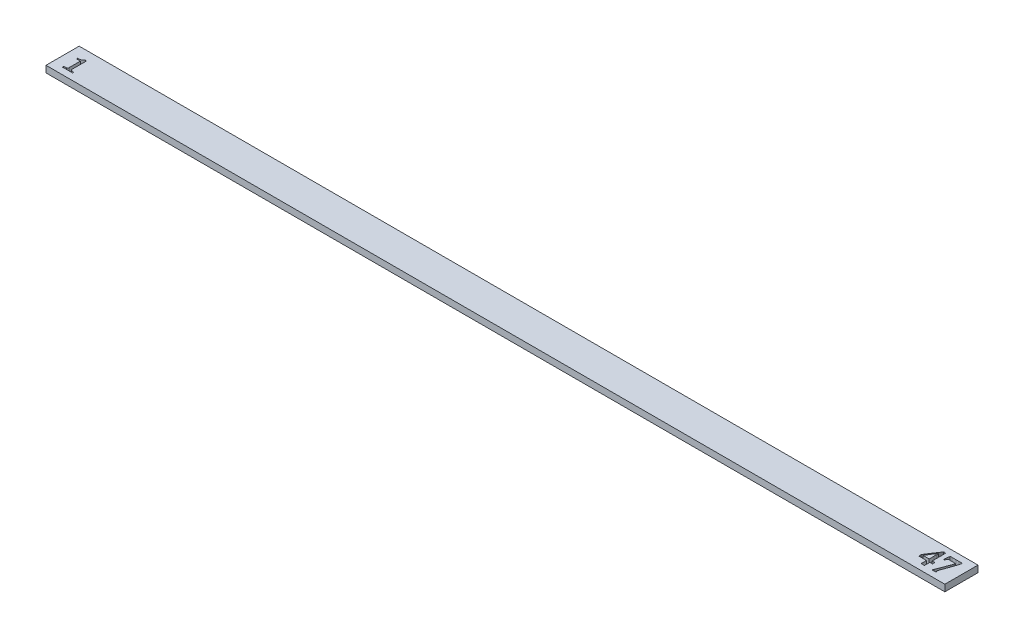
from build123d import *

# Parameters (mm, degrees)
SKETCH1_W               = 406.5
SKETCH1_H               = 15
BOSS_EXTRUDE1_DEPTH     = 3
CUT_EXTRUDE3_DEPTH      = 3
CUT_EXTRUDE4_DEPTH      = 1.0000001
CUT_EXTRUDE4_DEPTH_BACK = 4.0000001


with BuildPart() as part:
    # Sketch1 → Boss-Extrude1 (new body)
    with BuildSketch(Plane(origin=(0, 0, 0), x_dir=(1, 0, 0), z_dir=(0, 1, 0))):
        with Locations((203.25, 7.5)):
            Rectangle(SKETCH1_W, SKETCH1_H)
    extrude(amount=BOSS_EXTRUDE1_DEPTH)

    # Sketch6 → Cut-Extrude3 (cut)
    with BuildSketch(Plane(origin=(0, 3, 0), x_dir=(1, 0, 0), z_dir=(0, 1, 0))):
        with BuildLine():
            Line((9.066666667, 3), (4.4, 3))
            Line((4.4, 3), (4.4, 3.533333333))
            add(Edge.make_bspline(
                [(4.4, 3.533333333), (4.490588794, 3.537271225), (4.640939574, 3.554398669), (4.861223058, 3.573162067), (5.060458421, 3.593917618), (5.257445963, 3.613512622), (5.464614035, 3.645285276), (5.602979352, 3.665934489), (5.68125, 3.689583333)],
                knots=[0, 0, 0, 0, 0.2103903, 0.351266804, 0.513317769, 0.675537116, 0.81076344, 1, 1, 1, 1], degree=3))
            add(Edge.make_bspline(
                [(5.68125, 3.689583333), (5.748875075, 3.713315135), (5.846065039, 3.75657282), (5.954177233, 3.84358762), (6.019880095, 3.92035001), (6.074718504, 4.012338083), (6.121751402, 4.174441728), (6.136210364, 4.307279756), (6.133333333, 4.402083333)],
                knots=[0, 0, 0, 0, 0.235250595, 0.343488261, 0.45143933, 0.564460817, 0.690934998, 1, 1, 1, 1], degree=3))
            Line((6.133333333, 4.402083333), (6.133333333, 9.4))
            Line((6.133333333, 9.4), (4.4, 9.4))
            Line((4.4, 9.4), (4.4, 9.933333333))
            Line((4.4, 9.933333333), (4.770833333, 9.933333333))
            add(Edge.make_bspline(
                [(4.770833333, 9.933333333), (5.003253924, 9.932619455), (5.34569499, 9.96889158), (5.780241549, 10.092243553), (6.074213986, 10.222394513), (6.33996875, 10.370119885), (6.630202894, 10.569224178), (6.814157432, 10.739590824), (6.90625, 10.866666667)],
                knots=[0, 0, 0, 0, 0.289649108, 0.426683234, 0.561657866, 0.689592667, 0.805376187, 1, 1, 1, 1], degree=3))
            Line((6.90625, 10.866666667), (7.466666667, 10.866666667))
            add(Edge.make_bspline(
                [(7.466666667, 10.866666667), (7.466666667, 10.7), (7.466666667, 10.440277778), (7.466666667, 10.080555556), (7.466666667, 9.51875), (7.466666667, 9.05), (7.466666667, 8.68125)],
                knots=[0, 0, 0, 0, 0.228789323, 0.356530029, 0.493803622, 1, 1, 1, 1], degree=3))
            Line((7.466666667, 8.68125), (7.466666667, 4.477083333))
            add(Edge.make_bspline(
                [(7.466666667, 4.477083333), (7.465171299, 4.323802417), (7.508915415, 4.1322322), (7.627640514, 3.94057428), (7.725471426, 3.836074847), (7.81353907, 3.774674671), (7.879166667, 3.745833333)],
                knots=[0, 0, 0, 0, 0.518335827, 0.640811583, 0.758815486, 1, 1, 1, 1], degree=3))
            add(Edge.make_bspline(
                [(7.879166667, 3.745833333), (7.9542548, 3.71328483), (8.086144111, 3.677803773), (8.281176448, 3.634356203), (8.460811746, 3.603704136), (8.641304858, 3.575188457), (8.843360346, 3.550303966), (8.982249303, 3.535230482), (9.066666667, 3.533333333)],
                knots=[0, 0, 0, 0, 0.202205355, 0.337957571, 0.495327151, 0.653832039, 0.790920356, 1, 1, 1, 1], degree=3))
            Line((9.066666667, 3.533333333), (9.066666667, 3))
        make_face()
    extrude(amount=-CUT_EXTRUDE3_DEPTH, mode=Mode.SUBTRACT)

    # Sketch7 → Cut-Extrude4 (cut, two sides)
    with BuildSketch(Plane(origin=(0, 3, 0), x_dir=(1, 0, 0), z_dir=(0, 1, 0))) as cut_extrude4_sk:
        with BuildLine():
            Line((397.657416045, 12.134328358), (399.36170709, 12.119636194))
            Line((399.36170709, 12.119636194), (400.80363806, 12.134328358))
            Line((400.80363806, 12.134328358), (401.630597015, 12.134328358))
            Line((401.630597015, 12.134328358), (401.916044776, 12.134328358))
            add(Edge.make_bspline(
                [(401.916044776, 12.134328358), (402.048274254, 12.134328358), (402.180503731, 12.134328358)],
                knots=[0, 0, 0, 1, 1, 1], degree=2))
            add(Edge.make_bspline(
                [(402.180503731, 12.134328358), (402.201575998, 11.924942161), (402.201492537, 11.714552239)],
                knots=[0, 0, 0, 1, 1, 1], degree=2))
            add(Edge.make_bspline(
                [(402.201492537, 11.714552239), (402.203131347, 11.668589183), (402.19068364, 11.591838207), (402.174063032, 11.47775602), (402.152159642, 11.365919222), (402.12514035, 11.236424374), (402.077258352, 11.028335682), (402.035714677, 10.864320831), (402.006296642, 10.749067164)],
                knots=[0, 0, 0, 0, 0.13905043, 0.235945899, 0.350700723, 0.485483275, 0.63825942, 1, 1, 1, 1], degree=3))
            add(Edge.make_bspline(
                [(402.006296642, 10.749067164), (401.871316102, 10.385817027), (401.722590265, 9.935527531), (401.555047554, 9.414875731), (401.473187852, 9.159276866), (401.414575292, 8.9873101), (401.376632463, 8.885261194)],
                knots=[0, 0, 0, 0, 0.59075753, 0.723007296, 0.834001471, 1, 1, 1, 1], degree=3))
            add(Edge.make_bspline(
                [(401.376632463, 8.885261194), (401.313898269, 8.723451669), (401.204868261, 8.421855137), (401.103802997, 8.117485745), (401.061800373, 7.976445896)],
                knots=[0, 0, 0, 0, 0.541149528, 1, 1, 1, 1], degree=3))
            add(Edge.make_bspline(
                [(401.061800373, 7.976445896), (401.015781111, 7.867199658), (400.92613119, 7.624150454), (400.836545299, 7.38111444), (400.791044776, 7.248134328)],
                knots=[0, 0, 0, 0, 0.457478678, 1, 1, 1, 1], degree=3))
            Line((400.791044776, 7.248134328), (400.440531716, 6.251166045))
            add(Edge.make_bspline(
                [(400.440531716, 6.251166045), (400.401867219, 6.128988579), (400.289271875, 5.818532343), (400.177344913, 5.507885229), (400.104710821, 5.31926306)],
                knots=[0, 0, 0, 0, 0.387977624, 1, 1, 1, 1], degree=3))
            Line((400.104710821, 5.31926306), (399.531716418, 3.703125))
            add(Edge.make_bspline(
                [(399.531716418, 3.703125), (399.470792091, 3.588260157), (399.458255597, 3.459654851)],
                knots=[0, 0, 0, 1, 1, 1], degree=2))
            add(Edge.make_bspline(
                [(399.458255597, 3.459654851), (399.459359318, 3.418786808), (399.483917308, 3.355260387), (399.551474188, 3.28641717), (399.619265243, 3.234969283), (399.68890107, 3.185275189), (399.756975495, 3.118645064), (399.782530612, 3.05647035), (399.78358209, 3.016791045)],
                knots=[0, 0, 0, 0, 0.213120215, 0.343422421, 0.503306522, 0.66092689, 0.793754467, 1, 1, 1, 1], degree=3))
            add(Edge.make_bspline(
                [(399.78358209, 3.016791045), (399.782333582, 2.966918943), (399.738145153, 2.854647526), (399.649224406, 2.773694486), (399.596781716, 2.731343284)],
                knots=[0, 0, 0, 0, 0.419347253, 1, 1, 1, 1], degree=3))
            Line((399.596781716, 2.731343284), (399.414179104, 2.731343284))
            Line((399.414179104, 2.731343284), (398.887360075, 2.739738806))
            add(Edge.make_bspline(
                [(398.887360075, 2.739738806), (398.860151379, 2.742883209), (398.809019878, 2.741140263), (398.727094991, 2.742934339), (398.564977408, 2.731719862), (398.426269692, 2.734390124), (398.318563433, 2.731343284)],
                knots=[0, 0, 0, 0, 0.143976302, 0.269387033, 0.431850849, 1, 1, 1, 1], degree=3))
            add(Edge.make_bspline(
                [(398.318563433, 2.731343284), (398.177938433, 2.731343284), (398.037313433, 2.731343284)],
                knots=[0, 0, 0, 1, 1, 1], degree=2))
            add(Edge.make_bspline(
                [(398.037313433, 2.731343284), (398.049687067, 2.837793441), (398.135988461, 3.107690529), (398.252282772, 3.364778234), (398.324860075, 3.524720149)],
                knots=[0, 0, 0, 0, 0.377761085, 1, 1, 1, 1], degree=3))
            add(Edge.make_bspline(
                [(398.324860075, 3.524720149), (398.359194022, 3.604153438), (398.416976822, 3.739859696), (398.497461012, 3.945705724), (398.576766977, 4.150868746), (398.669922308, 4.390270462), (398.814377186, 4.778720373), (398.926619167, 5.087912153), (399.006996269, 5.304570896)],
                knots=[0, 0, 0, 0, 0.136189941, 0.232079304, 0.347806246, 0.482346311, 0.636338705, 1, 1, 1, 1], degree=3))
            Line((399.006996269, 5.304570896), (400.264225746, 8.69426306))
            Line((400.264225746, 8.69426306), (400.579057836, 9.559001866))
            add(Edge.make_bspline(
                [(400.579057836, 9.559001866), (400.616057825, 9.635348826), (400.685585318, 9.816861246), (400.749296629, 10.000359879), (400.782649254, 10.104710821)],
                knots=[0, 0, 0, 0, 0.436195377, 1, 1, 1, 1], degree=3))
            add(Edge.make_bspline(
                [(400.782649254, 10.104710821), (400.796446887, 10.155676607), (400.848863125, 10.278905641), (400.884307376, 10.408166699), (400.916977612, 10.482509328)],
                knots=[0, 0, 0, 0, 0.394055214, 1, 1, 1, 1], degree=3))
            add(Edge.make_bspline(
                [(400.916977612, 10.482509328), (400.707169462, 10.494052768), (400.331609443, 10.511600567), (399.95577418, 10.523472847), (399.789878731, 10.52238806)],
                knots=[0, 0, 0, 0, 0.558858828, 1, 1, 1, 1], degree=3))
            Line((399.789878731, 10.52238806), (398.734141791, 10.505597015))
            Line((398.734141791, 10.505597015), (397.890391791, 10.52238806))
            add(Edge.make_bspline(
                [(397.890391791, 10.52238806), (397.779523901, 10.519107819), (397.623281613, 10.516165209), (397.443939678, 10.457590251), (397.347926059, 10.402046043), (397.280071966, 10.318527079), (397.225882193, 10.21568689), (397.182311943, 10.088092188), (397.153666964, 9.944727335), (397.127648786, 9.805193063), (397.098045358, 9.686069457), (397.062105015, 9.598330089), (397.027739987, 9.531559532), (396.976868027, 9.493930387), (396.895857316, 9.451249493), (396.819667629, 9.45247622), (396.769589552, 9.447761194)],
                knots=[0, 0, 0, 0, 0.189212858, 0.259177039, 0.317618741, 0.37382617, 0.438411826, 0.513621268, 0.600883716, 0.685342077, 0.753932297, 0.80753941, 0.846294416, 0.878260495, 0.912652405, 1, 1, 1, 1], degree=3))
            add(Edge.make_bspline(
                [(396.769589552, 9.447761194), (396.709575572, 9.444087607), (396.572553162, 9.510974529), (396.561202473, 9.664537833), (396.559701493, 9.733208955)],
                knots=[0, 0, 0, 0, 0.447088882, 1, 1, 1, 1], degree=3))
            add(Edge.make_bspline(
                [(396.559701493, 9.733208955), (396.557663158, 9.882622623), (396.585872177, 10.242409551), (396.612263822, 10.602114141), (396.639458955, 10.812033582)],
                knots=[0, 0, 0, 0, 0.413664263, 1, 1, 1, 1], degree=3))
            add(Edge.make_bspline(
                [(396.639458955, 10.812033582), (396.674306511, 11.049653107), (396.71198534, 11.491672506), (396.756641484, 11.933109174), (396.788479478, 12.134328358)],
                knots=[0, 0, 0, 0, 0.541004894, 1, 1, 1, 1], degree=3))
            add(Edge.make_bspline(
                [(396.788479478, 12.134328358), (396.907416045, 12.134328358), (397.197061567, 12.134328358), (397.48670709, 12.134328358), (397.657416045, 12.134328358)],
                knots=[0, 0, 0, 0, 0.410628019, 1, 1, 1, 1], degree=3))
        make_face()
        with BuildLine():
            Line((395.753731343, 6.223880597), (395.753731343, 5.149253731))
            add(Edge.make_bspline(
                [(395.753731343, 5.149253731), (395.631296642, 5.149253731), (395.415811567, 5.149253731), (395.200326493, 5.149253731), (395.107276119, 5.149253731)],
                knots=[0, 0, 0, 0, 0.568181818, 1, 1, 1, 1], degree=3))
            add(Edge.make_bspline(
                [(395.107276119, 5.149253731), (394.826026119, 5.149253731), (394.544776119, 5.149253731)],
                knots=[0, 0, 0, 1, 1, 1], degree=2))
            add(Edge.make_bspline(
                [(394.544776119, 5.149253731), (394.544776119, 5.103078358), (394.544776119, 5.033815299), (394.544776119, 4.964552239), (394.544776119, 4.941464552)],
                knots=[0, 0, 0, 0, 0.666666667, 1, 1, 1, 1], degree=3))
            Line((394.544776119, 4.941464552), (394.544776119, 4.51329291))
            Line((394.544776119, 4.51329291), (394.544776119, 4.05573694))
            Line((394.544776119, 4.05573694), (394.544776119, 3.740904851))
            add(Edge.make_bspline(
                [(394.544776119, 3.740904851), (394.544776119, 3.690531716), (394.544776119, 3.547108209), (394.544776119, 3.403684701), (394.544776119, 3.310634328)],
                knots=[0, 0, 0, 0, 0.351219512, 1, 1, 1, 1], degree=3))
            add(Edge.make_bspline(
                [(394.544776119, 3.310634328), (394.544776119, 3.230177239), (394.544776119, 3.037080224), (394.544776119, 2.843983209), (394.544776119, 2.731343284)],
                knots=[0, 0, 0, 0, 0.416666667, 1, 1, 1, 1], degree=3))
            Line((394.544776119, 2.731343284), (393.940298507, 2.731343284))
            Line((393.940298507, 2.731343284), (393.566697761, 2.731343284))
            add(Edge.make_bspline(
                [(393.566697761, 2.731343284), (393.454407649, 2.731343284), (393.342117537, 2.731343284)],
                knots=[0, 0, 0, 1, 1, 1], degree=2))
            Line((393.342117537, 2.731343284), (393.222481343, 2.731343284))
            add(Edge.make_bspline(
                [(393.222481343, 2.731343284), (393.144822761, 2.731343284), (393.067164179, 2.731343284)],
                knots=[0, 0, 0, 1, 1, 1], degree=2))
            Line((393.067164179, 2.731343284), (393.067164179, 4.118703358))
            Line((393.067164179, 4.118703358), (393.067164179, 5.012826493))
            add(Edge.make_bspline(
                [(393.067164179, 5.012826493), (393.067164179, 5.081040112), (393.067164179, 5.149253731)],
                knots=[0, 0, 0, 1, 1, 1], degree=2))
            add(Edge.make_bspline(
                [(393.067164179, 5.149253731), (392.924440299, 5.149253731), (392.582322761, 5.149253731), (392.240205224, 5.149253731), (392.040811567, 5.149253731)],
                knots=[0, 0, 0, 0, 0.417177914, 1, 1, 1, 1], degree=3))
            Line((392.040811567, 5.149253731), (391.568563433, 5.149253731))
            add(Edge.make_bspline(
                [(391.568563433, 5.149253731), (390.890625, 5.149253731), (390.212686567, 5.149253731)],
                knots=[0, 0, 0, 1, 1, 1], degree=2))
            add(Edge.make_bspline(
                [(390.212686567, 5.149253731), (390.147621269, 5.149253731), (390.044776119, 5.149253731), (389.94193097, 5.149253731), (389.904151119, 5.149253731)],
                knots=[0, 0, 0, 0, 0.632653061, 1, 1, 1, 1], degree=3))
            add(Edge.make_bspline(
                [(389.904151119, 5.149253731), (389.739388993, 5.149253731), (389.574626866, 5.149253731)],
                knots=[0, 0, 0, 1, 1, 1], degree=2))
            Line((389.574626866, 5.149253731), (389.574626866, 5.220615672))
            Line((389.574626866, 5.220615672), (389.574626866, 5.671875))
            Line((389.574626866, 5.671875), (389.574626866, 5.816697761))
            Line((389.574626866, 5.816697761), (389.574626866, 6.085354478))
            Line((389.574626866, 6.085354478), (389.574626866, 6.137826493))
            add(Edge.make_bspline(
                [(389.574626866, 6.137826493), (389.623782796, 6.244403893), (389.693615111, 6.39626409), (389.786162448, 6.585468576), (389.842247315, 6.702586567), (389.890429815, 6.801289218), (389.939191492, 6.898328094), (389.971418955, 6.962783636), (389.994402985, 6.998367537)],
                knots=[0, 0, 0, 0, 0.367667449, 0.523514139, 0.659760796, 0.774435554, 0.867544135, 1, 1, 1, 1], degree=3))
            Line((389.994402985, 6.998367537), (391.650419776, 9.559001866))
            add(Edge.make_bspline(
                [(391.650419776, 9.559001866), (391.807055602, 9.806282448), (392.03909514, 10.144078632), (392.324760311, 10.565502776), (392.502153351, 10.807634783), (392.650609206, 11.013917219), (392.803139644, 11.22584384), (392.900401458, 11.374305928), (392.955923507, 11.464785448)],
                knots=[0, 0, 0, 0, 0.379956122, 0.532152195, 0.660988778, 0.769655013, 0.862163026, 1, 1, 1, 1], degree=3))
            add(Edge.make_bspline(
                [(392.955923507, 11.464785448), (393.018372607, 11.562095513), (393.121998043, 11.741678016), (393.246076675, 11.907653743), (393.300139925, 11.981110075)],
                knots=[0, 0, 0, 0, 0.55903442, 1, 1, 1, 1], degree=3))
            add(Edge.make_bspline(
                [(393.300139925, 11.981110075), (393.358943812, 12.063224967), (393.461858879, 12.190417263), (393.550113092, 12.328105409), (393.581389925, 12.381996269)],
                knots=[0, 0, 0, 0, 0.61851227, 1, 1, 1, 1], degree=3))
            add(Edge.make_bspline(
                [(393.581389925, 12.381996269), (393.687973018, 12.382177604), (393.851160041, 12.402008298), (394.015204614, 12.400139253), (394.072527985, 12.402985075)],
                knots=[0, 0, 0, 0, 0.649820797, 1, 1, 1, 1], degree=3))
            add(Edge.make_bspline(
                [(394.072527985, 12.402985075), (394.132647323, 12.400207034), (394.290437013, 12.4025118), (394.447312533, 12.38301176), (394.544776119, 12.381996269)],
                knots=[0, 0, 0, 0, 0.381893514, 1, 1, 1, 1], degree=3))
            Line((394.544776119, 12.381996269), (394.544776119, 12.293843284))
            Line((394.544776119, 12.293843284), (394.544776119, 11.746035448))
            Line((394.544776119, 11.746035448), (394.544776119, 11.555037313))
            Line((394.544776119, 11.555037313), (394.544776119, 11.250699627))
            Line((394.544776119, 11.250699627), (394.544776119, 10.948460821))
            Line((394.544776119, 10.948460821), (394.544776119, 10.215951493))
            Line((394.544776119, 10.215951493), (394.544776119, 9.899020522))
            Line((394.544776119, 9.899020522), (394.544776119, 9.483442164))
            Line((394.544776119, 9.483442164), (394.544776119, 9.099347015))
            Line((394.544776119, 9.099347015), (394.544776119, 8.574626866))
            Line((394.544776119, 8.574626866), (394.544776119, 8.072994403))
            Line((394.544776119, 8.072994403), (394.544776119, 7.487406716))
            Line((394.544776119, 7.487406716), (394.544776119, 6.223880597))
            add(Edge.make_bspline(
                [(394.544776119, 6.223880597), (394.875349813, 6.223880597), (395.205923507, 6.223880597)],
                knots=[0, 0, 0, 1, 1, 1], degree=2))
            Line((395.205923507, 6.223880597), (395.388526119, 6.223880597))
            add(Edge.make_bspline(
                [(395.388526119, 6.223880597), (395.571128731, 6.223880597), (395.753731343, 6.223880597)],
                knots=[0, 0, 0, 1, 1, 1], degree=2))
        make_face()
        with BuildLine():
            Line((393.067164179, 7.43073694), (393.067164179, 7.995335821))
            Line((393.067164179, 7.995335821), (393.067164179, 8.480177239))
            Line((393.067164179, 8.480177239), (393.073460821, 9.733208955))
            Line((393.073460821, 9.733208955), (393.067164179, 10.306203358))
            add(Edge.make_bspline(
                [(393.067164179, 10.306203358), (393.065373822, 10.346876212), (393.075433631, 10.460028929), (393.076017407, 10.573560777), (393.081856343, 10.646222015)],
                knots=[0, 0, 0, 0, 0.357983602, 1, 1, 1, 1], degree=3))
            add(Edge.make_bspline(
                [(393.081856343, 10.646222015), (392.987918553, 10.510875926), (392.880363806, 10.385960821)],
                knots=[0, 0, 0, 1, 1, 1], degree=2))
            add(Edge.make_bspline(
                [(392.880363806, 10.385960821), (392.80628152, 10.256935511), (392.716651119, 10.13829291)],
                knots=[0, 0, 0, 1, 1, 1], degree=2))
            add(Edge.make_bspline(
                [(392.716651119, 10.13829291), (392.614918684, 10.011248227), (392.400543107, 9.729031505), (392.199117887, 9.437421574), (392.093283582, 9.277751866)],
                knots=[0, 0, 0, 0, 0.459339067, 1, 1, 1, 1], degree=3))
            Line((392.093283582, 9.277751866), (391.448927239, 8.234608209))
            add(Edge.make_bspline(
                [(391.448927239, 8.234608209), (391.341452073, 8.066790517), (391.24113806, 7.894589552)],
                knots=[0, 0, 0, 1, 1, 1], degree=2))
            add(Edge.make_bspline(
                [(391.24113806, 7.894589552), (391.091296084, 7.647321822), (390.762215539, 7.150814848), (390.45540342, 6.639149775), (390.330223881, 6.358208955)],
                knots=[0, 0, 0, 0, 0.485063777, 1, 1, 1, 1], degree=3))
            add(Edge.make_bspline(
                [(390.330223881, 6.358208955), (390.391791045, 6.358208955), (390.49113806, 6.358208955), (390.590485075, 6.358208955), (390.628264925, 6.358208955)],
                knots=[0, 0, 0, 0, 0.61971831, 1, 1, 1, 1], degree=3))
            Line((390.628264925, 6.358208955), (390.978777985, 6.358208955))
            Line((390.978777985, 6.358208955), (391.677705224, 6.358208955))
            Line((391.677705224, 6.358208955), (392.651585821, 6.358208955))
            Line((392.651585821, 6.358208955), (393.067164179, 6.358208955))
            add(Edge.make_bspline(
                [(393.067164179, 6.358208955), (393.067164179, 6.463852612), (393.067164179, 6.64505597), (393.067164179, 6.826259328), (393.067164179, 6.90181903)],
                knots=[0, 0, 0, 0, 0.583011583, 1, 1, 1, 1], degree=3))
            add(Edge.make_bspline(
                [(393.067164179, 6.90181903), (393.067164179, 6.992070896), (393.067164179, 7.112406716), (393.067164179, 7.257229478), (393.067164179, 7.343283582), (393.067164179, 7.399253731), (393.067164179, 7.43073694)],
                knots=[0, 0, 0, 0, 0.511904762, 0.682539683, 0.821428571, 1, 1, 1, 1], degree=3))
        make_face(mode=Mode.SUBTRACT)
    extrude(amount=CUT_EXTRUDE4_DEPTH, mode=Mode.SUBTRACT)
    extrude(cut_extrude4_sk.sketch, amount=-CUT_EXTRUDE4_DEPTH_BACK, mode=Mode.SUBTRACT)


solid = part.part
